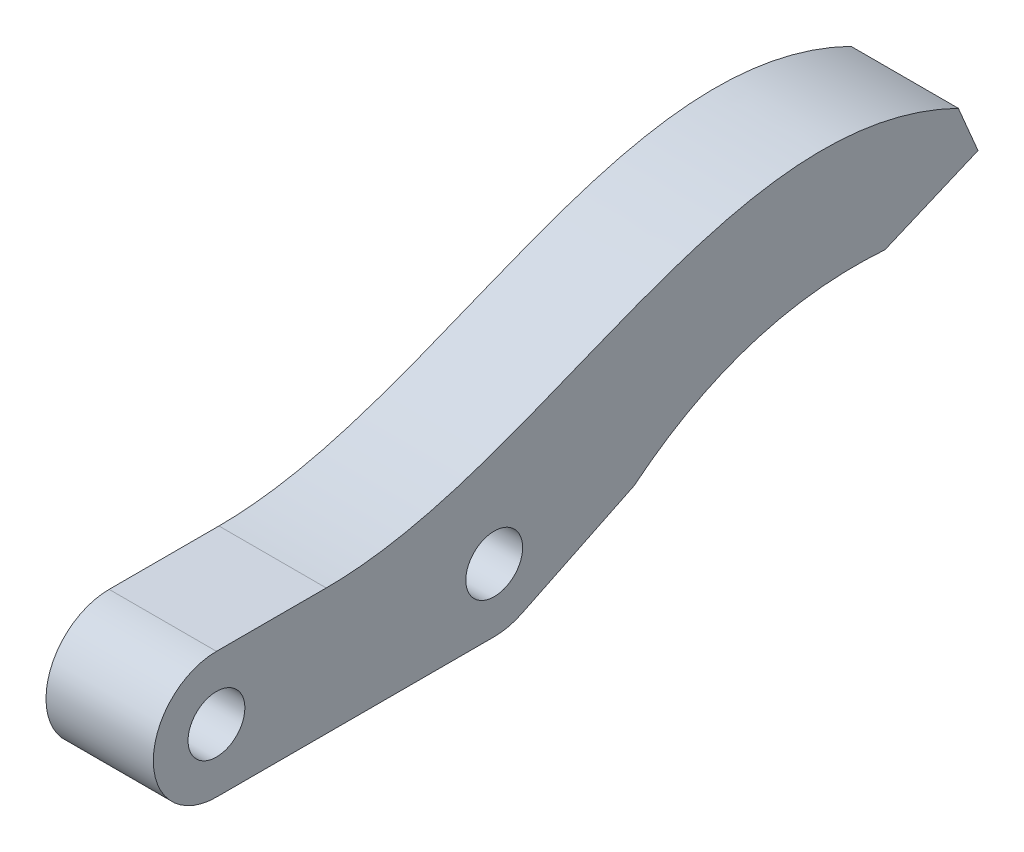
from build123d import *

# Parameters (mm, degrees)
SKETCH1_R           = 2.25
BOSS_EXTRUDE1_DEPTH = 8.5
BOSS_EXTRUDE2_DEPTH = 8.5


with BuildPart() as part:
    # Sketch1 → Boss-Extrude1 (new body)
    with BuildSketch(Plane(origin=(0, 0, 0), x_dir=(0, 0, -1), z_dir=(1, 0, 0))):
        with BuildLine():
            Line((27, 10), (5, 10))
            ThreePointArc((5, 10), (0, 5), (5, 0))
            Line((5, 0), (27, 0))
            ThreePointArc((27, 0), (32, 5), (27, 10))
        make_face()
        with Locations((5, 5)):
            Circle(SKETCH1_R, mode=Mode.SUBTRACT)
        with Locations((27, 5)):
            Circle(SKETCH1_R, mode=Mode.SUBTRACT)
    extrude(amount=BOSS_EXTRUDE1_DEPTH)

    # Sketch2 → Boss-Extrude2 (add)
    with BuildSketch(Plane(origin=(8.5, 0, 0), x_dir=(0, 0, -1), z_dir=(1, 0, 0))):
        with BuildLine():
            add(Edge.make_bspline(
                [(63.752972286, 17.872423117), (45.928882678, 26.563787963), (31.059268621, 10), (13.694974759, 10)],
                knots=[0, 0, 0, 0, 1, 1, 1, 1], degree=3))
            Line((13.694974759, 10), (27, 10))
            ThreePointArc((27, 10), (31.87285141, 6.120410255), (29.183837075, 0.502127655))
            Line((29.183837075, 0.502127655), (38.08542066, 4.824084077))
            add(Edge.make_bspline(
                [(38.08542066, 4.824084077), (46.797509509, 11.895222457), (57.948000409, 11.067843667)],
                knots=[0, 0, 0, 1, 1, 1], degree=2))
            Line((57.948000409, 11.067843667), (65.313809691, 14.189518476))
            Line((65.313809691, 14.189518476), (63.752972286, 17.872423117))
        make_face()
    extrude(amount=-BOSS_EXTRUDE2_DEPTH)


solid = part.part
